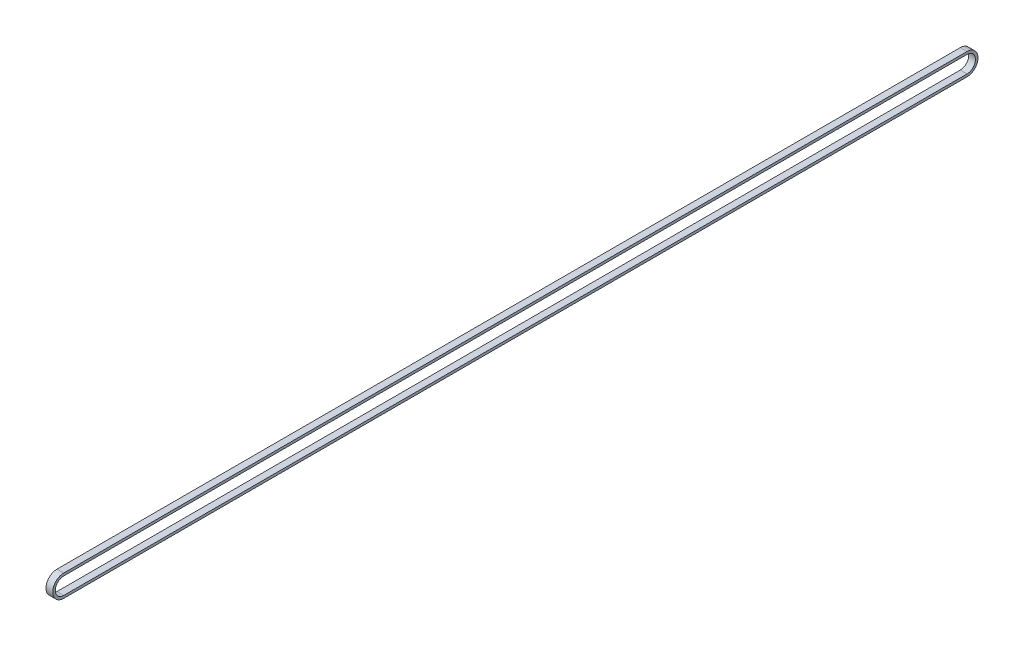
from build123d import *

# Parameters (mm, degrees)
EXTRUDE_1_DEPTH = 8


with BuildPart() as part:
    # 草图1 → 凸台-拉伸1 (new body)
    with BuildSketch(Plane(origin=(0, 0, 0), x_dir=(0, 0, -1), z_dir=(1, 0, 0))):
        with BuildLine():
            Line((0, 23), (1070, 23))
            ThreePointArc((1070, 23), (1083, 10), (1070, -3))
            Line((1070, -3), (0, -3))
            ThreePointArc((0, -3), (-13, 10), (0, 23))
        make_face()
        with BuildLine():
            Line((0, 0), (1070, 0))
            ThreePointArc((1070, 0), (1080, 10), (1070, 20))
            Line((1070, 20), (0, 20))
            ThreePointArc((0, 20), (-10, 10), (0, 0))
        make_face(mode=Mode.SUBTRACT)
    extrude(amount=EXTRUDE_1_DEPTH)


solid = part.part
